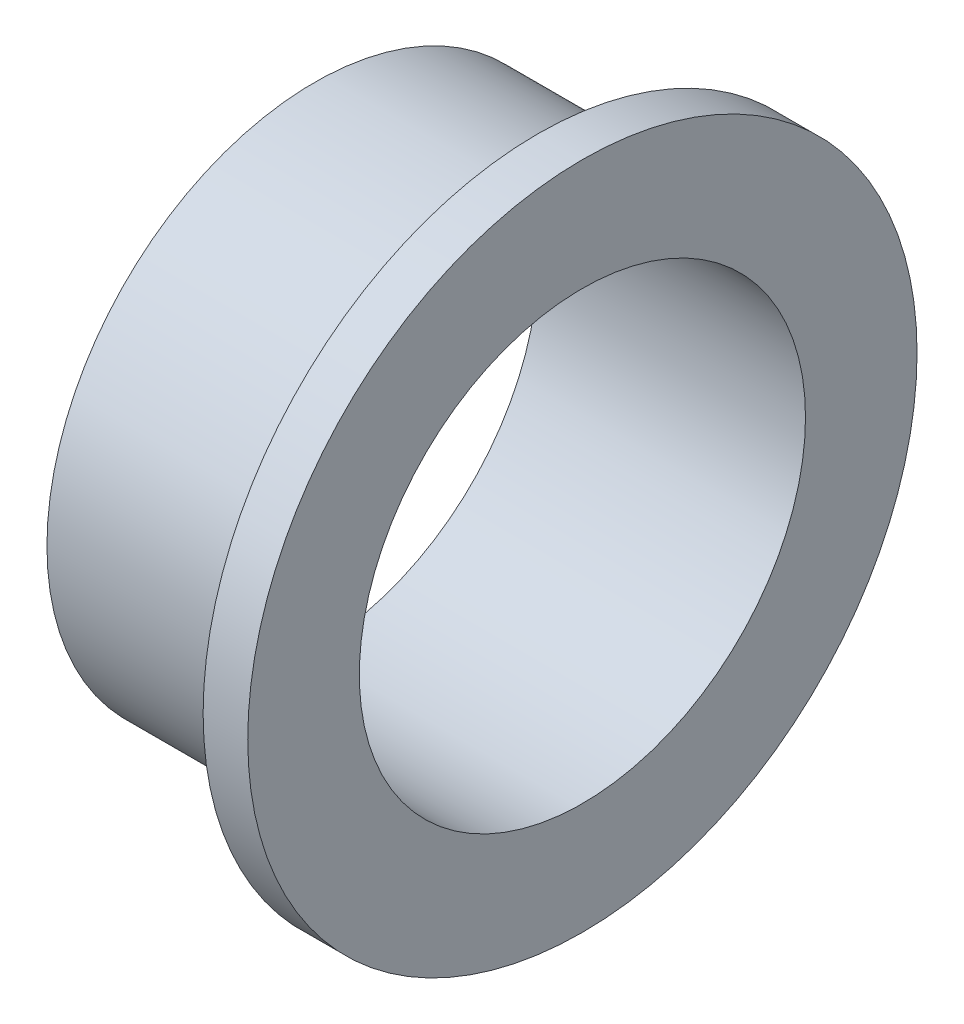
from build123d import *


with BuildPart() as part:
    # Skizze1 → Rotation1 (revolve)
    with BuildSketch(Plane.XY):
        Polygon((-6, 5), (0, 5), (0, 7.5), (-1, 7.5), (-1, 6), (-6, 6), align=None)
    revolve(axis=Axis((-6.676457764, 0, 0), (-1, 0, 0)))


solid = part.part
